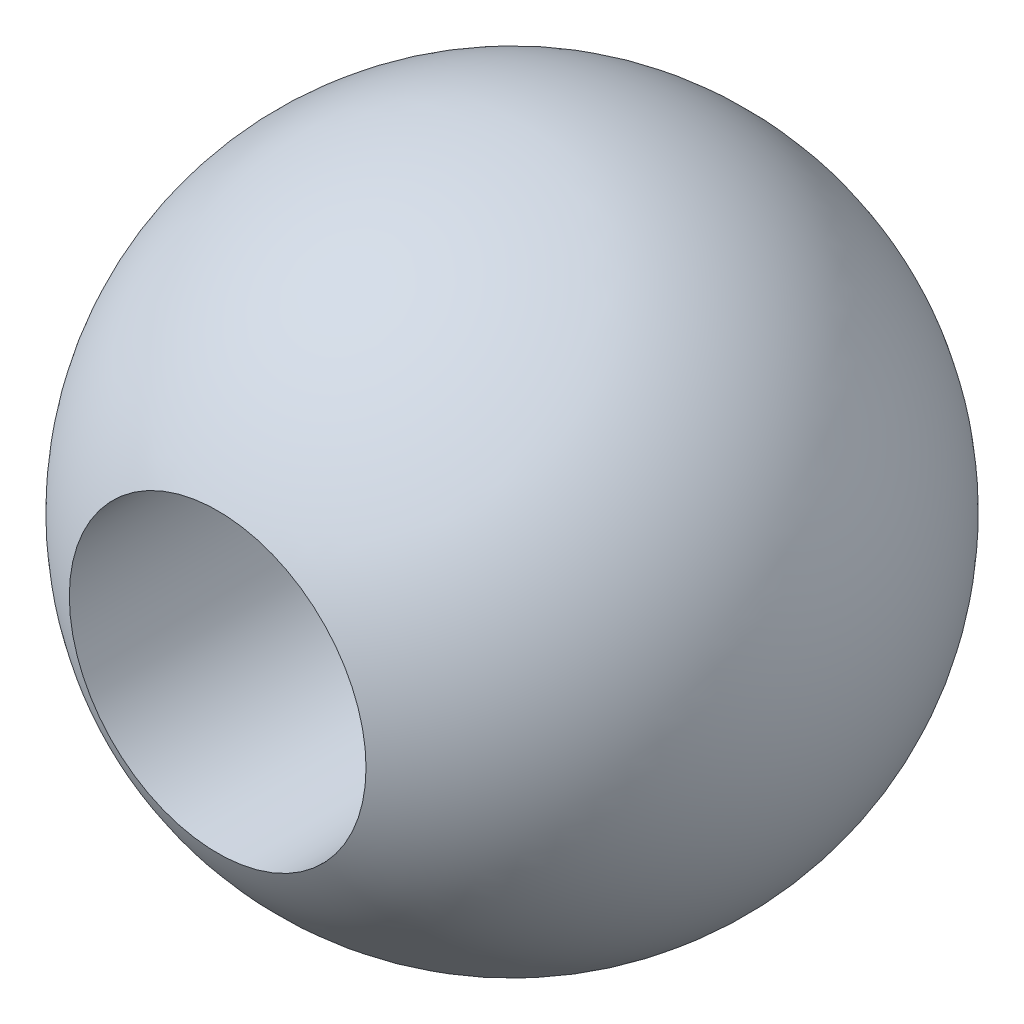
from build123d import *

# Parameters (mm, degrees)
SKETCH3_R               = 2.5
CUT_EXTRUDE1_DEPTH      = 6.555
CUT_EXTRUDE1_DEPTH_BACK = 6.555


with BuildPart() as part:
    # Sketch2 → Revolve3 (revolve)
    with BuildSketch(Plane.XY):
        with BuildLine():
            Line((0, 5.555), (0, -5.555))
            ThreePointArc((0, -5.555), (-5.555, 0), (0, 5.555))
        make_face()
    revolve(axis=Axis((0, 0, 0), (0, 1, 0)))

    # Sketch3 → Cut-Extrude1 (cut, two sides)
    with BuildSketch(Plane.XY) as cut_extrude1_sk:
        Circle(SKETCH3_R)
    extrude(amount=CUT_EXTRUDE1_DEPTH, mode=Mode.SUBTRACT)
    extrude(cut_extrude1_sk.sketch, amount=-CUT_EXTRUDE1_DEPTH_BACK, mode=Mode.SUBTRACT)


solid = part.part
